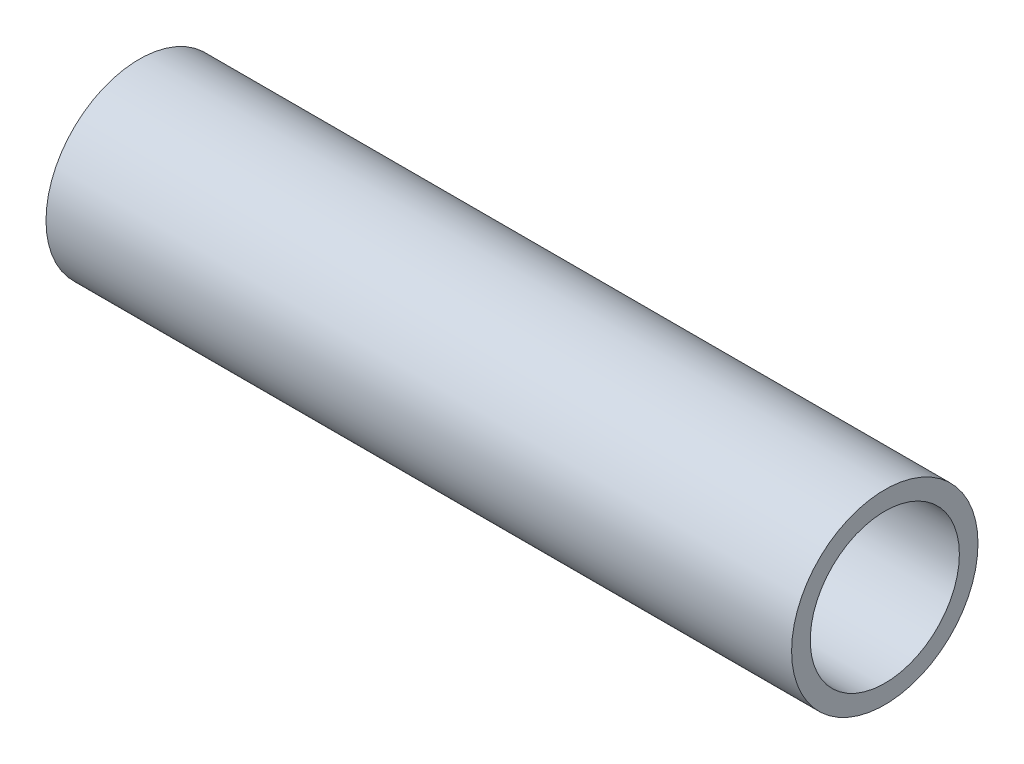
from build123d import *

# Parameters (mm, degrees)
SKETCH_1_R      = 5
SKETCH_1_R_2    = 4
EXTRUDE_1_DEPTH = 40


with BuildPart() as part:
    # 草图1 → 凸台-拉伸1 (new body)
    with BuildSketch(Plane(origin=(0, 0, 0), x_dir=(0, 0, -1), z_dir=(1, 0, 0))):
        Circle(SKETCH_1_R)
        Circle(SKETCH_1_R_2, mode=Mode.SUBTRACT)
    extrude(amount=EXTRUDE_1_DEPTH)


solid = part.part
